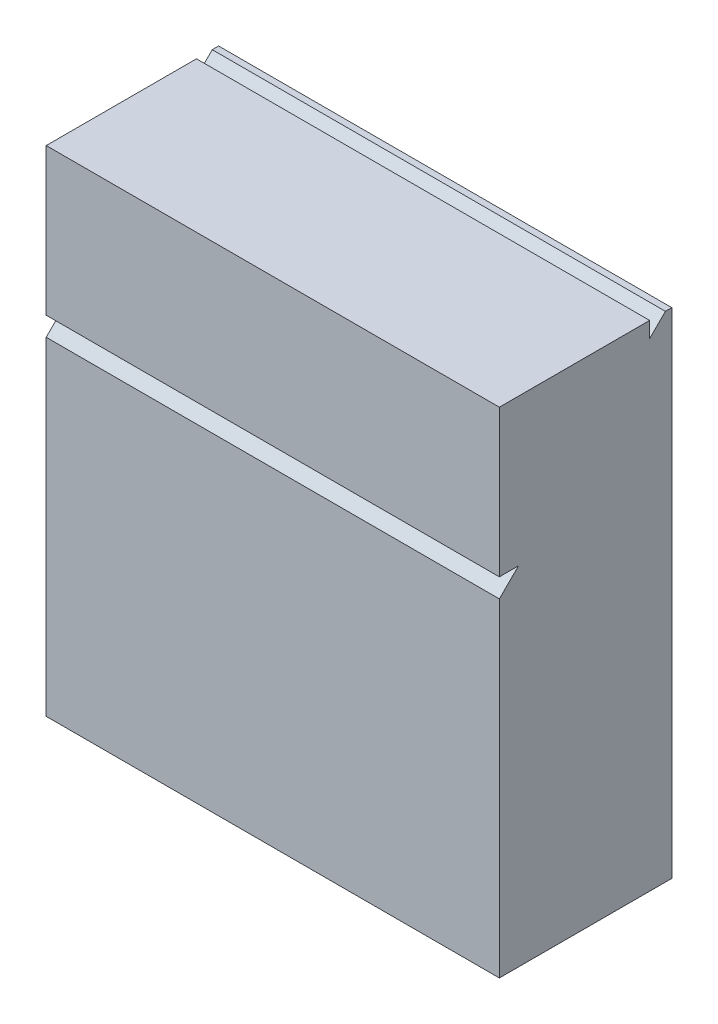
from build123d import *

# Parameters (mm, degrees)
SKETCH1_W               = 22
SKETCH1_H               = 24
BOSS_EXTRUDE1_DEPTH     = 8.371
CUT_EXTRUDE2_DEPTH      = 1
CUT_EXTRUDE2_DEPTH_BACK = 23
BOSS_EXTRUDE3_DEPTH     = 22


with BuildPart() as part:
    # Sketch1 → Boss-Extrude1 (new body)
    with BuildSketch(Plane.XY):
        Rectangle(SKETCH1_W, SKETCH1_H)
    extrude(amount=BOSS_EXTRUDE1_DEPTH)

    # Sketch5 → Cut-Extrude2 (cut, two sides)
    with BuildSketch(Plane(origin=(11, 0, 0), x_dir=(0, 0, -1), z_dir=(1, 0, 0))) as cut_extrude2_sk:
        Polygon((42.565554112, 54.875536807), (-0.309982694, 12), (-8.371, 3.938982694), (-51.246536807, -38.936554112), (-136.99761042, 46.814519501), (-43.185519501, 140.62661042), align=None)
    extrude(amount=CUT_EXTRUDE2_DEPTH, mode=Mode.SUBTRACT)
    extrude(cut_extrude2_sk.sketch, amount=-CUT_EXTRUDE2_DEPTH_BACK, mode=Mode.SUBTRACT)

    # Sketch6 → Boss-Extrude3 (add, through all)
    with BuildSketch(Plane(origin=(11, 0, 0), x_dir=(0, 0, -1), z_dir=(1, 0, 0))):
        Polygon((-8.371, 12), (-1.075372561, 12), (-1.075372561, 11.234610134), (-7.444138152, 4.865844542), (-8.371, 4.865844542), align=None)
    extrude(amount=-BOSS_EXTRUDE3_DEPTH)


solid = part.part
